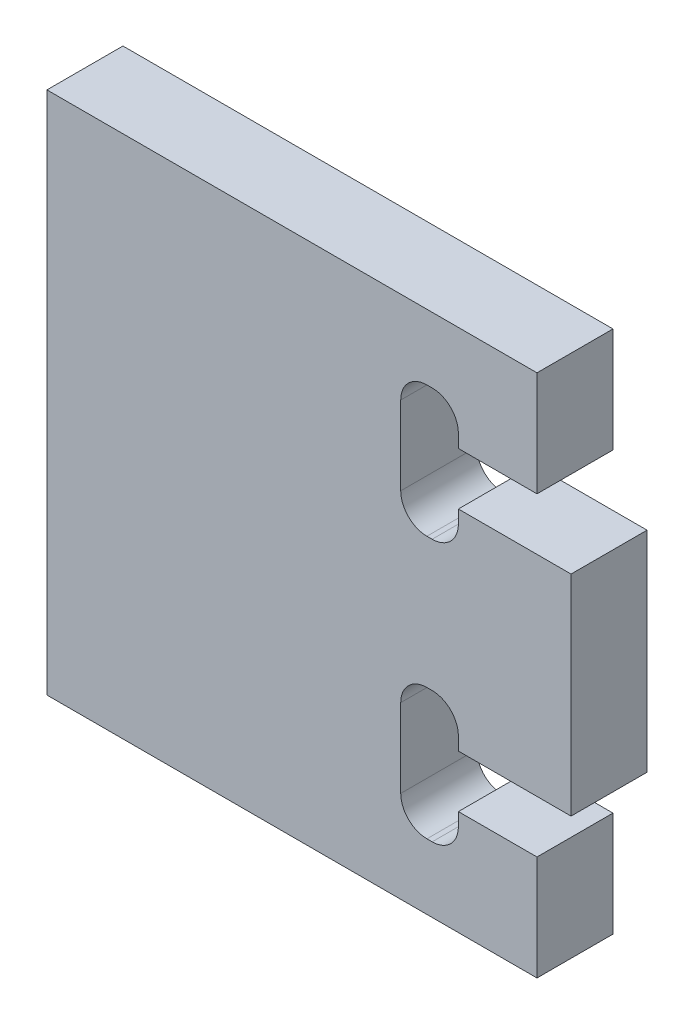
from build123d import *

# Parameters (mm, degrees)
BASE_SHAPE_DEPTH       = 2.9
SKETCH2_R              = 5
FORWARD_CUT_TEMP_DEPTH = 1
FILLET1_R              = 1
CUT_EXTRUDE1_REACH     = 44.108
SKETCH4_W              = 61.6
SKETCH4_H              = 20


with BuildPart() as part:
    # Sketch1 → Base shape (new body)
    with BuildSketch(Plane.XY):
        Polygon((39.5, 10), (-39.5, 10), (-39.5, 6), (-36.5, 6), (-36.5, 7.5), (-34.3, 7.5), (-34.3, 2.5), (-36.5, 2.5), (-36.5, 4), (-40.8, 4), (-40.8, -4), (-36.5, -4), (-36.5, -2.5), (-34.3, -2.5), (-34.3, -7.5), (-36.5, -7.5), (-36.5, -6), (-39.5, -6), (-39.5, -10), (39.5, -10), (39.5, -6), (36.5, -6), (36.5, -7.5), (34.3, -7.5), (34.3, -2.5), (36.5, -2.5), (36.5, -4), (40.8, -4), (40.8, 4), (36.5, 4), (36.5, 2.5), (34.3, 2.5), (34.3, 7.5), (36.5, 7.5), (36.5, 6), (39.5, 6), align=None)
    extrude(amount=BASE_SHAPE_DEPTH)

    # Sketch2 → Forward cut _temp (cut)
    with BuildSketch(Plane.XY.offset(2.9)):
        Circle(SKETCH2_R)
    extrude(amount=-FORWARD_CUT_TEMP_DEPTH, mode=Mode.SUBTRACT)

    # Fillet1
    fillet1_edges = [part.edges().sort_by_distance(p)[0] for p in [
        (36.5, -7.5, 1.45),
        (36.5, 2.5, 1.45),
        (34.3, 2.5, 1.45),
        (34.3, -7.5, 1.45),
        (36.5, -2.5, 1.45),
        (36.5, 7.5, 1.45),
        (34.3, -2.5, 1.45),
        (34.3, 7.5, 1.45),
        (-36.5, -2.5, 1.45),
        (-34.3, -2.5, 1.45),
        (-34.3, -7.5, 1.45),
        (-36.5, -7.5, 1.45),
        (-36.5, 2.5, 1.45),
        (-34.3, 2.5, 1.45),
        (-34.3, 7.5, 1.45),
        (-36.5, 7.5, 1.45),
    ]]
    fillet(fillet1_edges, radius=FILLET1_R)

    # Sketch4 → Cut-Extrude1 (cut, up to next)
    with BuildSketch(Plane.XY.offset(2.9), mode=Mode.PRIVATE) as cut_extrude1_sk1:
        with Locations((-10, 0)):
            Rectangle(SKETCH4_W, SKETCH4_H)
    cut_extrude1_tool1 = extrude(cut_extrude1_sk1.sketch, amount=-CUT_EXTRUDE1_REACH, mode=Mode.PRIVATE) & part.part
    add(cut_extrude1_tool1.solids().sort_by_distance((-10, 0, 2.9))[0], mode=Mode.SUBTRACT)


solid = part.part
